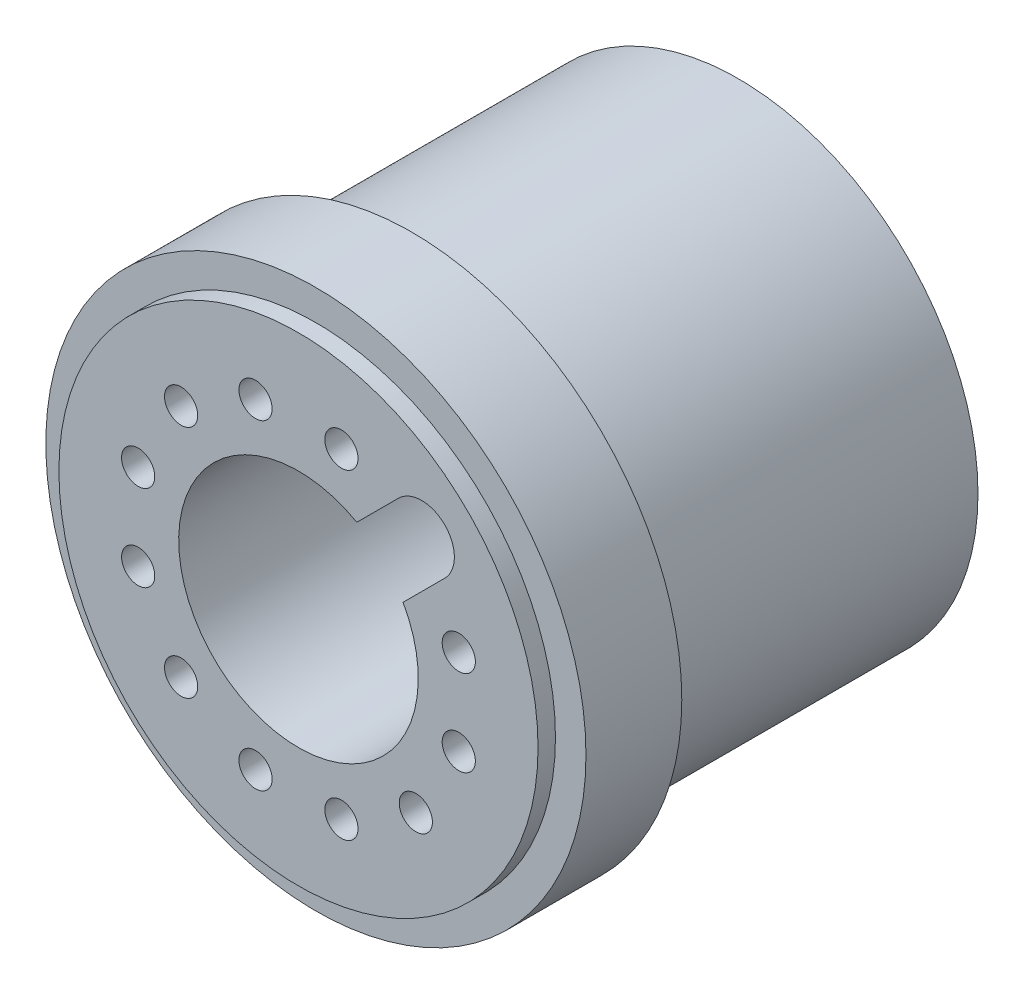
from build123d import *

# Parameters (mm, degrees)
SKETCH_1_R               = 6.2
SKETCH_1_R_2             = 2.75
EXTRUDE_1_DEPTH          = 2.2
SKETCH_1_5_R             = 5.5
SKETCH_1_5_R_2           = 2.75
EXTRUDE_3_DEPTH          = 7.5
EXTRUDE_START            = 2.2
SKETCH_1_6_R             = 5.5
SKETCH_1_6_R_2           = 2.75
EXTRUDE_4_DEPTH          = 0.4
SKETCH_2_R               = 0.381
CUT_EXTRUDE_1_DEPTH      = 14.374976635
PATTERN_CIRCULAR_1_COUNT = 12
CUT_EXTRUDE_2_DEPTH      = 2


with BuildPart() as part:
    # Sketch 1 → Extrude 1 (new body)
    with BuildSketch(Plane.XY):
        Circle(SKETCH_1_R)
        Circle(SKETCH_1_R_2, mode=Mode.SUBTRACT)
    extrude(amount=EXTRUDE_1_DEPTH)

    # Sketch 1_5 → Extrude 3 (add)
    with BuildSketch(Plane.XY):
        Circle(SKETCH_1_5_R)
        Circle(SKETCH_1_5_R_2, mode=Mode.SUBTRACT)
    extrude(amount=-EXTRUDE_3_DEPTH)

    # Sketch 1_6 → Extrude 4 (add)
    with BuildSketch(Plane.XY.offset(EXTRUDE_START)):
        Circle(SKETCH_1_6_R)
        Circle(SKETCH_1_6_R_2, mode=Mode.SUBTRACT)
    extrude(amount=EXTRUDE_4_DEPTH)

    # Sketch 2 → Cut-Extrude 1 (cut, through all)
    with BuildSketch(Plane.XY.offset(2.6)):
        with Locations((0.986100562, 3.680177398)):
            Circle(SKETCH_2_R)
    cut_extrude_1 = extrude(amount=-CUT_EXTRUDE_1_DEPTH, mode=Mode.SUBTRACT)

    # Pattern Circular 1: Cut-Extrude 1 ×12 about axis, 1 skipped
    pattern_circular_1_axis = Axis((0, 0, 0), (0, 0, 1))
    add([cut_extrude_1.rotate(pattern_circular_1_axis, i * 360 / PATTERN_CIRCULAR_1_COUNT) for i in range(1, PATTERN_CIRCULAR_1_COUNT) if i not in (11,)], mode=Mode.SUBTRACT)

    # Sketch 4 → Cut-Extrude 2 (cut)
    with BuildSketch(Plane.XY.offset(2.6)):
        with BuildLine():
            ThreePointArc((1.340498607, 2.401158779), (1.944543648, 1.944543648), (2.401158779, 1.340498607))
            Line((2.401158779, 1.340498607), (3.358757211, 2.298097039))
            ThreePointArc((3.358757211, 2.298097039), (3.358757211, 3.358757211), (2.298097039, 3.358757211))
            Line((2.298097039, 3.358757211), (1.340498607, 2.401158779))
        make_face()
    extrude(amount=-CUT_EXTRUDE_2_DEPTH, mode=Mode.SUBTRACT)


solid = part.part
